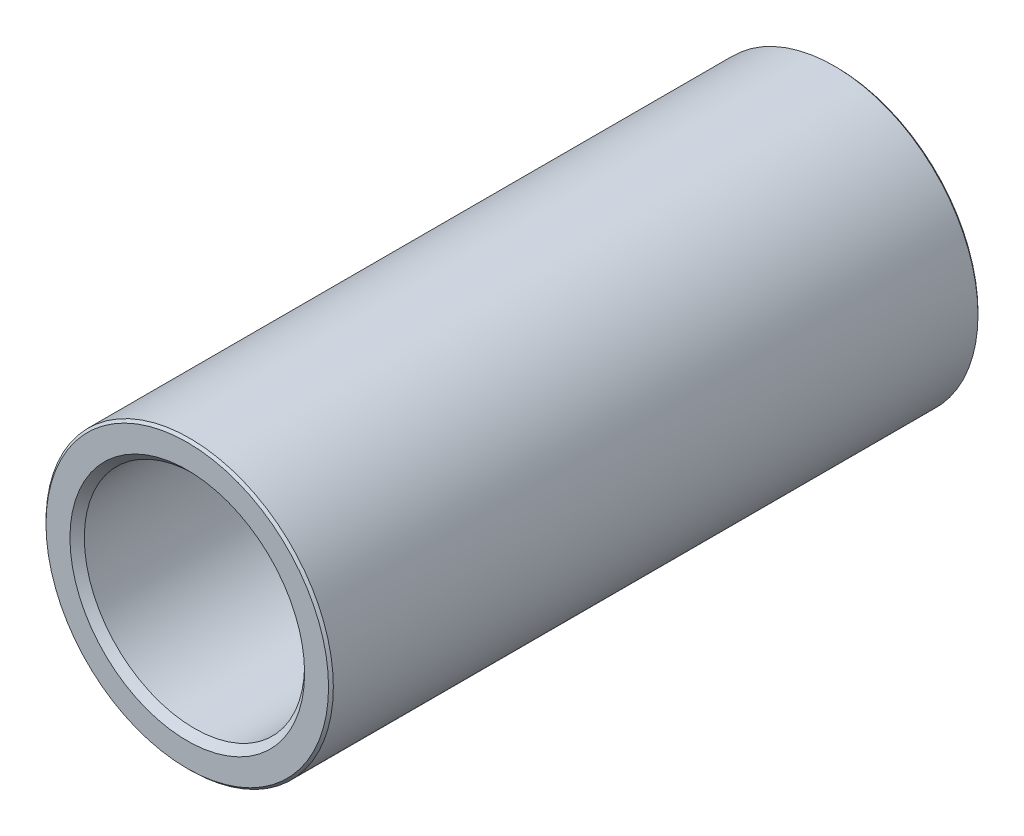
from build123d import *

# Parameters (mm, degrees)
SKETCH1_R           = 15
SKETCH1_R_2         = 11.5
BOSS_EXTRUDE1_DEPTH = 67.8072
CHAMFER1_SIZE       = 0.25
CHAMFER2_SIZE       = 0.75


with BuildPart() as part:
    # Sketch1 → Boss-Extrude1 (new body)
    with BuildSketch(Plane.XY):
        Circle(SKETCH1_R)
        Circle(SKETCH1_R_2, mode=Mode.SUBTRACT)
    extrude(amount=BOSS_EXTRUDE1_DEPTH)

    # Chamfer1
    chamfer1_edges = [part.edges().sort_by_distance(p)[0] for p in [
        (-15, 0, 0),
        (-15, 0, 67.8072),
    ]]
    chamfer(chamfer1_edges, length=CHAMFER1_SIZE)

    # Chamfer2
    chamfer2_edges = [part.edges().sort_by_distance(p)[0] for p in [
        (-11.5, 0, 0),
        (-11.5, 0, 67.8072),
    ]]
    chamfer(chamfer2_edges, length=CHAMFER2_SIZE)


solid = part.part
